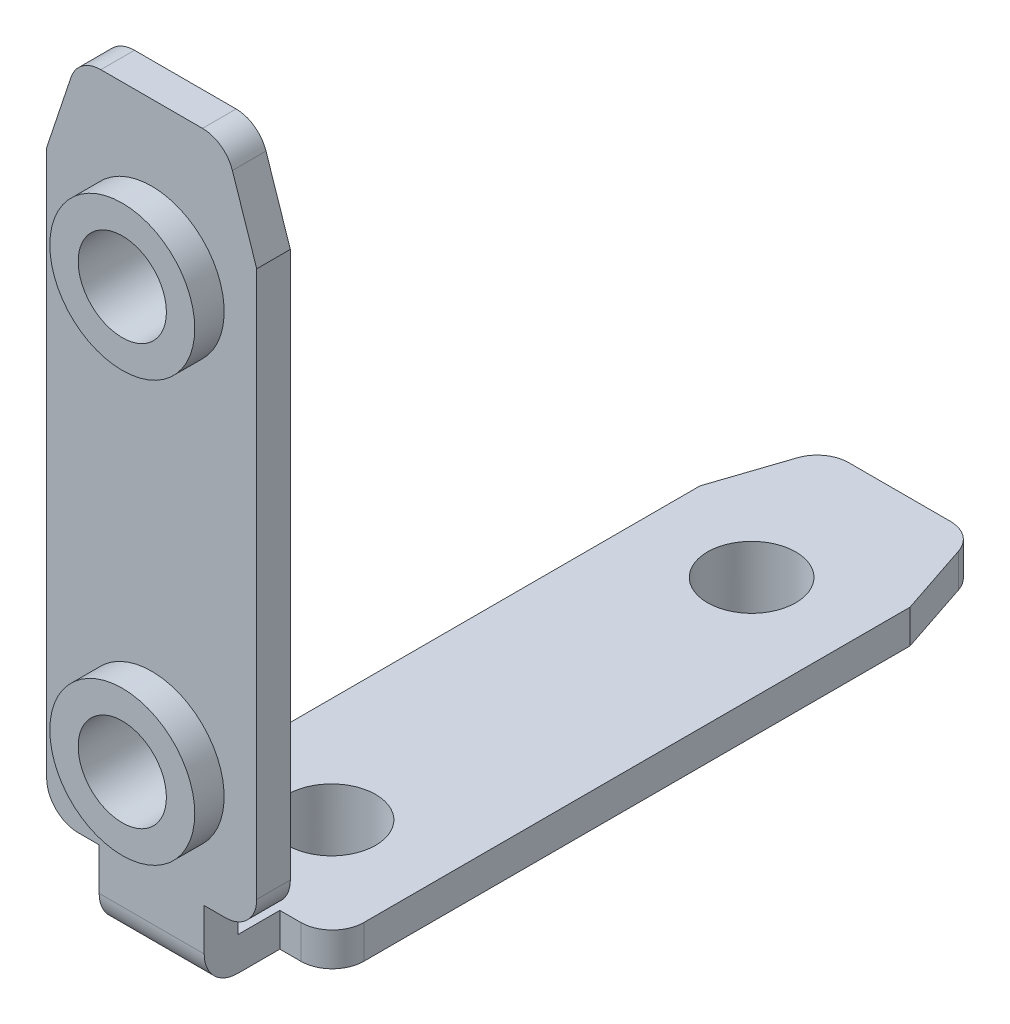
from build123d import *

# Parameters (mm, degrees)
BOSS_EXTRUDE1_DEPTH   = 1.6
SKETCH2_R             = 3.45
BOSS_EXTRUDE2_DEPTH   = 1.4
M5X0_8_TAPPED_HOLE1_D = 4.2
BOSS_EXTRUDE3_DEPTH   = 5


with BuildPart() as part:
    # Sketch1 → Boss-Extrude1 (new body)
    with BuildSketch(Plane.XY):
        with BuildLine():
            Line((-3.5, 2), (-2.5, 2))
            Line((-2.5, 2), (-2.5, 0))
            Line((-2.5, 0), (2.5, 0))
            Line((2.5, 0), (2.5, 2))
            Line((2.5, 2), (3.5, 2))
            ThreePointArc((3.5, 2), (4.560660172, 2.439339828), (5, 3.5))
            Line((5, 3.5), (5, 29.5))
            Line((5, 29.5), (3.841886117, 32.974341649))
            ThreePointArc((3.841886117, 32.974341649), (3.295926597, 33.716863278), (2.41886117, 34))
            Line((2.41886117, 34), (-2.41886117, 34))
            ThreePointArc((-2.41886117, 34), (-3.295926597, 33.716863278), (-3.841886117, 32.974341649))
            Line((-3.841886117, 32.974341649), (-5, 29.5))
            Line((-5, 29.5), (-5, 3.5))
            ThreePointArc((-5, 3.5), (-4.560660172, 2.439339828), (-3.5, 2))
        make_face()
    boss_extrude1 = extrude(amount=BOSS_EXTRUDE1_DEPTH)

    # Sketch2 → Boss-Extrude2 (add)
    with BuildSketch(Plane.XY.offset(1.6)):
        with Locations((0, 6.96)):
            Circle(SKETCH2_R)
        with Locations((0, 26.96)):
            Circle(SKETCH2_R)
    boss_extrude2 = extrude(amount=BOSS_EXTRUDE2_DEPTH)

    # M5x0.8 Tapped Hole1 (through all)
    with Locations(Plane.XY.offset(3)):
        with Locations((0, 26.96), (0, 6.96)):
            m5x0_8_tapped_hole1 = Hole(M5X0_8_TAPPED_HOLE1_D / 2)

    # Sketch5 → Boss-Extrude3 (add)
    with BuildSketch(Plane(origin=(2.5, 0, 0), x_dir=(0, 0, -1), z_dir=(1, 0, 0))):
        with BuildLine():
            Line((0, 0), (-1.6, 0))
            ThreePointArc((-1.6, 0), (-1.13137085, -1.13137085), (0, -1.6))
            Line((0, -1.6), (0, 0))
        make_face()
    extrude(amount=-BOSS_EXTRUDE3_DEPTH)

    # Mirror4: Boss-Extrude1, Boss-Extrude2, M5x0.8 Tapped Hole1 across plane
    add(boss_extrude1.mirror(Plane(origin=(0, 0, 0), x_dir=(0, -0.707106781, 0.707106781), z_dir=(0, -0.707106781, -0.707106781))))
    add(boss_extrude2.mirror(Plane(origin=(0, 0, 0), x_dir=(0, -0.707106781, 0.707106781), z_dir=(0, -0.707106781, -0.707106781))))
    add(m5x0_8_tapped_hole1.mirror(Plane(origin=(0, 0, 0), x_dir=(0, -0.707106781, 0.707106781), z_dir=(0, -0.707106781, -0.707106781))), mode=Mode.SUBTRACT)


solid = part.part
